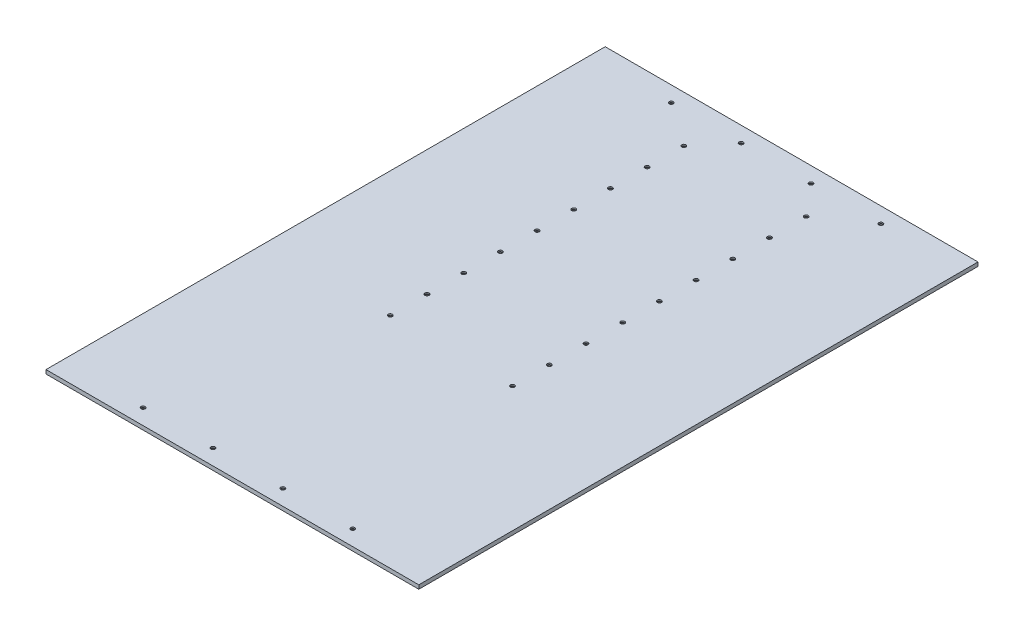
from build123d import *

# Parameters (mm, degrees)
SKETCH1_W                                            = 609.6
SKETCH1_H                                            = 914.4
BOSS_EXTRUDE1_DEPTH                                  = 6.35
CBORE_FOR_1_4_BINDING_HEAD_MACHINE_SCREW_D           = 6.7564
CBORE_FOR_1_4_BINDING_HEAD_MACHINE_SCREW_CBORE_D     = 14.2875
CBORE_FOR_1_4_BINDING_HEAD_MACHINE_SCREW_CBORE_DEPTH = 4.191
LPATTERN1_COUNT                                      = 4
LPATTERN1_PITCH                                      = 114.3
CBORE_FOR_1_4_BINDING_HEAD_MACHINE_S_2_D             = 6.7564
CBORE_FOR_1_4_BINDING_HEAD_MACHINE_S_2_CBORE_D       = 14.2875
CBORE_FOR_1_4_BINDING_HEAD_MACHINE_S_2_CBORE_DEPTH   = 4.191
LPATTERN2_COUNT                                      = 4
LPATTERN2_PITCH                                      = 114.3
CBORE_FOR_1_4_BINDING_HEAD_MACHINE_S_3_D             = 6.7564
CBORE_FOR_1_4_BINDING_HEAD_MACHINE_S_3_CBORE_D       = 14.2875
CBORE_FOR_1_4_BINDING_HEAD_MACHINE_S_3_CBORE_DEPTH   = 4.191
LPATTERN3_COUNT                                      = 2
LPATTERN3_PITCH                                      = 200
LPATTERN3_COUNT_DIR2                                 = 9
LPATTERN3_PITCH_DIR2                                 = 60


with BuildPart() as part:
    # Sketch1 → Boss-Extrude1 (new body)
    with BuildSketch(Plane(origin=(0, 0, 0), x_dir=(1, 0, 0), z_dir=(0, 1, 0))):
        Rectangle(SKETCH1_W, SKETCH1_H)
    extrude(amount=BOSS_EXTRUDE1_DEPTH)

    # CBORE for 1_4 Binding Head Machine Screw (through all)
    with Locations(Plane.XZ):
        with Locations((-171.45, 431.8)):
            cbore_for_1_4_binding_head_machine_screw = CounterBoreHole(CBORE_FOR_1_4_BINDING_HEAD_MACHINE_SCREW_D / 2, CBORE_FOR_1_4_BINDING_HEAD_MACHINE_SCREW_CBORE_D / 2, CBORE_FOR_1_4_BINDING_HEAD_MACHINE_SCREW_CBORE_DEPTH)

    # LPattern1: CBORE for 1_4 Binding Head Machine Screw ×4
    with Locations(*[(i * LPATTERN1_PITCH, 0, 0) for i in range(1, LPATTERN1_COUNT)]):
        add(cbore_for_1_4_binding_head_machine_screw, mode=Mode.SUBTRACT)

    # CBORE for 1_4 Binding Head Machine S 2 (through all)
    with Locations(Plane.XZ):
        with Locations((171.45, -431.8)):
            cbore_for_1_4_binding_head_machine_s_2 = CounterBoreHole(CBORE_FOR_1_4_BINDING_HEAD_MACHINE_S_2_D / 2, CBORE_FOR_1_4_BINDING_HEAD_MACHINE_S_2_CBORE_D / 2, CBORE_FOR_1_4_BINDING_HEAD_MACHINE_S_2_CBORE_DEPTH)

    # LPattern2: CBORE for 1_4 Binding Head Machine S 2 ×4
    with Locations(*[(-i * LPATTERN2_PITCH, 0, 0) for i in range(1, LPATTERN2_COUNT)]):
        add(cbore_for_1_4_binding_head_machine_s_2, mode=Mode.SUBTRACT)

    # CBORE for 1_4 Binding Head Machine S 3 (through all)
    with Locations(Plane.XZ):
        with Locations((-100, -381)):
            cbore_for_1_4_binding_head_machine_s_3 = CounterBoreHole(CBORE_FOR_1_4_BINDING_HEAD_MACHINE_S_3_D / 2, CBORE_FOR_1_4_BINDING_HEAD_MACHINE_S_3_CBORE_D / 2, CBORE_FOR_1_4_BINDING_HEAD_MACHINE_S_3_CBORE_DEPTH)

    # LPattern3: CBORE for 1_4 Binding Head Machine S 3 2 × 9
    with Locations(*[(i * LPATTERN3_PITCH, 0, j * LPATTERN3_PITCH_DIR2) for i in range(LPATTERN3_COUNT) for j in range(LPATTERN3_COUNT_DIR2) if (i, j) != (0, 0)]):
        add(cbore_for_1_4_binding_head_machine_s_3, mode=Mode.SUBTRACT)


solid = part.part
